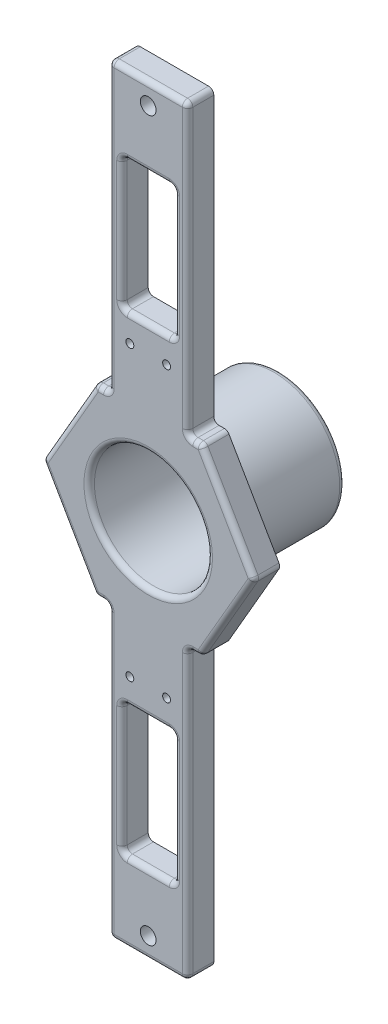
from build123d import *

# Parameters (mm, degrees)
BOSS_EXTRUDE2_DEPTH = 10
SKETCH4_W           = 30
SKETCH4_H           = 110
SKETCH4_R           = 1.5
BOSS_EXTRUDE4_DEPTH = 10
SKETCH5_R           = 3
CUT_EXTRUDE3_DEPTH  = 5
SKETCH6_W           = 4
SKETCH6_H           = 2
SKETCH6_W_2         = 2
SKETCH6_H_2         = 4
CUT_EXTRUDE4_DEPTH  = 4
CUT_EXTRUDE7_REACH  = 12
SKETCH13_W          = 20
SKETCH13_H          = 50
FILLET4_R           = 2
SKETCH14_R          = 25
BOSS_EXTRUDE5_DEPTH = 40
SKETCH15_R          = 22.5
CUT_EXTRUDE8_DEPTH  = 45
CUT_EXTRUDE9_REACH  = 52
SKETCH16_R          = 9
CUT_EXTRUDE10_REACH = 52
SKETCH17_R          = 2
FILLET5_R           = 2
FILLET6_R           = 2
CUT_EXTRUDE11_REACH = 52
CUT_EXTRUDE12_REACH = 52
SKETCH19_R          = 1.5
SKETCH20_R          = 3
CUT_EXTRUDE13_DEPTH = 5


with BuildPart() as part:
    # Sketch1 → Boss-Extrude2 (new body)
    with BuildSketch(Plane.XY):
        Polygon((20.207259422, 35), (-20.207259422, 35), (-40.414518843, 0), (-20.207259422, -35), (20.207259422, -35), (40.414518843, 0), align=None)
    extrude(amount=BOSS_EXTRUDE2_DEPTH)

    # Sketch4 → Boss-Extrude4 (add)
    with BuildSketch(Plane(origin=(0, 0, 0), x_dir=(-1, 0, 0), z_dir=(0, 0, -1))):
        with Locations((0, 90)):
            Rectangle(SKETCH4_W, SKETCH4_H)
        with Locations((0, 137)):
            Circle(SKETCH4_R, mode=Mode.SUBTRACT)
        with Locations((0, -90)):
            Rectangle(SKETCH4_W, SKETCH4_H)
        with Locations((0, -137)):
            Circle(SKETCH4_R, mode=Mode.SUBTRACT)
    extrude(amount=-BOSS_EXTRUDE4_DEPTH)

    # Sketch5 → Cut-Extrude3 (cut)
    with BuildSketch(Plane.XY.offset(10)):
        with Locations((0, 137)):
            Circle(SKETCH5_R)
        with Locations((0, -137)):
            Circle(SKETCH5_R)
    extrude(amount=-CUT_EXTRUDE3_DEPTH, mode=Mode.SUBTRACT)

    # Sketch6 → Cut-Extrude4 (cut)
    with BuildSketch(Plane(origin=(0, 0, 0), x_dir=(-1, 0, 0), z_dir=(0, 0, -1))):
        with Locations((5, 137)):
            Rectangle(SKETCH6_W, SKETCH6_H)
        with Locations((0, 142)):
            Rectangle(SKETCH6_W_2, SKETCH6_H_2)
        with Locations((0, 132)):
            Rectangle(SKETCH6_W_2, SKETCH6_H_2)
        with Locations((-5, 137)):
            Rectangle(SKETCH6_W, SKETCH6_H)
        with Locations((0, -132)):
            Rectangle(SKETCH6_W_2, SKETCH6_H_2)
        with Locations((5, -137)):
            Rectangle(SKETCH6_W, SKETCH6_H)
        with Locations((-5, -137)):
            Rectangle(SKETCH6_W, SKETCH6_H)
        with Locations((0, -142)):
            Rectangle(SKETCH6_W_2, SKETCH6_H_2)
    extrude(amount=-CUT_EXTRUDE4_DEPTH, mode=Mode.SUBTRACT)

    # Sketch13 → Cut-Extrude7 (cut, up to next)
    with BuildSketch(Plane.XY.offset(10), mode=Mode.PRIVATE) as cut_extrude7_sk1:
        with Locations((0, 90)):
            Rectangle(SKETCH13_W, SKETCH13_H)
    cut_extrude7_tool1 = extrude(cut_extrude7_sk1.sketch, amount=-CUT_EXTRUDE7_REACH, mode=Mode.PRIVATE) & part.part
    add(cut_extrude7_tool1.solids().sort_by_distance((0, 90, 10))[0], mode=Mode.SUBTRACT)
    # Sketch13 → Cut-Extrude7 (cut, up to next)
    with BuildSketch(Plane.XY.offset(10), mode=Mode.PRIVATE) as cut_extrude7_sk2:
        with Locations((0, -90)):
            Rectangle(SKETCH13_W, SKETCH13_H)
    cut_extrude7_tool2 = extrude(cut_extrude7_sk2.sketch, amount=-CUT_EXTRUDE7_REACH, mode=Mode.PRIVATE) & part.part
    add(cut_extrude7_tool2.solids().sort_by_distance((0, -90, 10))[0], mode=Mode.SUBTRACT)

    # Fillet4
    fillet4_edges = [part.edges().sort_by_distance(p)[0] for p in [
        (40.414518843, 0, 5),
        (20.207259422, -35, 5),
        (-20.207259422, -35, 5),
        (-40.414518843, 0, 5),
        (-20.207259422, 35, 5),
        (20.207259422, 35, 5),
        (-30.310889132, 17.5, 10),
        (-30.310889132, -17.5, 10),
        (-10, 65, 5),
        (-10, 115, 5),
        (10, 115, 5),
        (10, 65, 5),
        (-10, 90, 10),
        (0, 65, 10),
        (10, 90, 10),
        (0, 115, 10),
        (10, -65, 5),
        (10, -115, 5),
        (-10, -115, 5),
        (-10, -65, 5),
        (10, -90, 10),
        (0, -65, 10),
        (-10, -90, 10),
        (0, -115, 10),
        (-17.603629711, -35, 10),
        (17.603629711, -35, 10),
        (-17.603629711, 35, 10),
        (30.310889132, -17.5, 10),
        (15, 90, 10),
        (15, 35, 5),
        (0, 145, 10),
        (15, 145, 5),
        (-15, 90, 10),
        (-15, 145, 5),
        (-15, 35, 5),
        (15, -90, 10),
        (15, -145, 5),
        (15, -35, 5),
        (-15, -90, 10),
        (-15, -35, 5),
        (0, -145, 10),
        (-15, -145, 5),
        (30.310889132, 17.5, 10),
        (17.603629711, 35, 10),
    ]]
    fillet(fillet4_edges, radius=FILLET4_R)

    # Sketch14 → Boss-Extrude5 (add)
    with BuildSketch(Plane(origin=(0, 0, 0), x_dir=(-1, 0, 0), z_dir=(0, 0, -1))):
        Circle(SKETCH14_R)
    extrude(amount=BOSS_EXTRUDE5_DEPTH)

    # Sketch15 → Cut-Extrude8 (cut)
    with BuildSketch(Plane.XY.offset(10)):
        Circle(SKETCH15_R)
    extrude(amount=-CUT_EXTRUDE8_DEPTH, mode=Mode.SUBTRACT)

    # Sketch16 → Cut-Extrude9 (cut, up to next)
    with BuildSketch(Plane(origin=(0, 0, -40), x_dir=(-1, 0, 0), z_dir=(0, 0, -1)), mode=Mode.PRIVATE) as cut_extrude9_sk1:
        Circle(SKETCH16_R)
    cut_extrude9_tool1 = extrude(cut_extrude9_sk1.sketch, amount=-CUT_EXTRUDE9_REACH, mode=Mode.PRIVATE) & part.part
    add(cut_extrude9_tool1.solids().sort_by_distance((0, 0, -40))[0], mode=Mode.SUBTRACT)

    # Sketch17 → Cut-Extrude10 (cut, up to next)
    with BuildSketch(Plane(origin=(0, 0, -40), x_dir=(-1, 0, 0), z_dir=(0, 0, -1)), mode=Mode.PRIVATE) as cut_extrude10_sk1:
        with Locations((-14.5, 0)):
            Circle(SKETCH17_R)
    cut_extrude10_tool1 = extrude(cut_extrude10_sk1.sketch, amount=-CUT_EXTRUDE10_REACH, mode=Mode.PRIVATE) & part.part
    add(cut_extrude10_tool1.solids().sort_by_distance((14.5, 0, -40))[0], mode=Mode.SUBTRACT)
    # Sketch17 → Cut-Extrude10 (cut, up to next)
    with BuildSketch(Plane(origin=(0, 0, -40), x_dir=(-1, 0, 0), z_dir=(0, 0, -1)), mode=Mode.PRIVATE) as cut_extrude10_sk2:
        with Locations((14.5, 0)):
            Circle(SKETCH17_R)
    cut_extrude10_tool2 = extrude(cut_extrude10_sk2.sketch, amount=-CUT_EXTRUDE10_REACH, mode=Mode.PRIVATE) & part.part
    add(cut_extrude10_tool2.solids().sort_by_distance((-14.5, 0, -40))[0], mode=Mode.SUBTRACT)

    # Fillet5
    fillet5_edges = [part.edges().sort_by_distance(p)[0] for p in [
        (25, 0, -40),
    ]]
    fillet(fillet5_edges, radius=FILLET5_R)

    # Fillet6
    fillet6_edges = [part.edges().sort_by_distance(p)[0] for p in [
        (-22.5, 0, 10),
    ]]
    fillet(fillet6_edges, radius=FILLET6_R)

    # Sketch18 → Cut-Extrude11 (cut, up to next)
    with BuildSketch(Plane(origin=(0, 0, -40), x_dir=(-1, 0, 0), z_dir=(0, 0, -1)), mode=Mode.PRIVATE) as cut_extrude11_sk1:
        with BuildLine():
            Line((14.654211885, 7.583144073), (11.10167567, 5.744806116))
            ThreePointArc((11.10167567, 5.744806116), (8.838834765, 8.838834765), (5.744806116, 11.10167567))
            Line((5.744806116, 11.10167567), (7.583144073, 14.654211885))
            ThreePointArc((7.583144073, 14.654211885), (11.66726189, 11.66726189), (14.654211885, 7.583144073))
        make_face()
    cut_extrude11_tool1 = extrude(cut_extrude11_sk1.sketch, amount=-CUT_EXTRUDE11_REACH, mode=Mode.PRIVATE) & part.part
    add(cut_extrude11_tool1.solids().sort_by_distance((-10.155842, 10.155842, -40))[0], mode=Mode.SUBTRACT)
    # Sketch18 → Cut-Extrude11 (cut, up to next)
    with BuildSketch(Plane(origin=(0, 0, -40), x_dir=(-1, 0, 0), z_dir=(0, 0, -1)), mode=Mode.PRIVATE) as cut_extrude11_sk2:
        with BuildLine():
            Line((14.654211885, -7.583144073), (11.10167567, -5.744806116))
            ThreePointArc((11.10167567, -5.744806116), (8.838834765, -8.838834765), (5.744806116, -11.10167567))
            Line((5.744806116, -11.10167567), (7.583144073, -14.654211885))
            ThreePointArc((7.583144073, -14.654211885), (11.66726189, -11.66726189), (14.654211885, -7.583144073))
        make_face()
    cut_extrude11_tool2 = extrude(cut_extrude11_sk2.sketch, amount=-CUT_EXTRUDE11_REACH, mode=Mode.PRIVATE) & part.part
    add(cut_extrude11_tool2.solids().sort_by_distance((-10.155842, -10.155842, -40))[0], mode=Mode.SUBTRACT)
    # Sketch18 → Cut-Extrude11 (cut, up to next)
    with BuildSketch(Plane(origin=(0, 0, -40), x_dir=(-1, 0, 0), z_dir=(0, 0, -1)), mode=Mode.PRIVATE) as cut_extrude11_sk3:
        with BuildLine():
            Line((-7.583144073, -14.654211885), (-5.744806116, -11.10167567))
            ThreePointArc((-5.744806116, -11.10167567), (-8.838834765, -8.838834765), (-11.10167567, -5.744806116))
            Line((-11.10167567, -5.744806116), (-14.654211885, -7.583144073))
            ThreePointArc((-14.654211885, -7.583144073), (-11.66726189, -11.66726189), (-7.583144073, -14.654211885))
        make_face()
    cut_extrude11_tool3 = extrude(cut_extrude11_sk3.sketch, amount=-CUT_EXTRUDE11_REACH, mode=Mode.PRIVATE) & part.part
    add(cut_extrude11_tool3.solids().sort_by_distance((10.155842, -10.155842, -40))[0], mode=Mode.SUBTRACT)
    # Sketch18 → Cut-Extrude11 (cut, up to next)
    with BuildSketch(Plane(origin=(0, 0, -40), x_dir=(-1, 0, 0), z_dir=(0, 0, -1)), mode=Mode.PRIVATE) as cut_extrude11_sk4:
        with BuildLine():
            Line((-14.654211885, 7.583144073), (-11.10167567, 5.744806116))
            ThreePointArc((-11.10167567, 5.744806116), (-8.838834765, 8.838834765), (-5.744806116, 11.10167567))
            Line((-5.744806116, 11.10167567), (-7.583144073, 14.654211885))
            ThreePointArc((-7.583144073, 14.654211885), (-11.66726189, 11.66726189), (-14.654211885, 7.583144073))
        make_face()
    cut_extrude11_tool4 = extrude(cut_extrude11_sk4.sketch, amount=-CUT_EXTRUDE11_REACH, mode=Mode.PRIVATE) & part.part
    add(cut_extrude11_tool4.solids().sort_by_distance((10.155842, 10.155842, -40))[0], mode=Mode.SUBTRACT)

    # Sketch19 → Cut-Extrude12 (cut, up to next)
    with BuildSketch(Plane.XY.offset(10), mode=Mode.PRIVATE) as cut_extrude12_sk1:
        with Locations((-7, 55)):
            Circle(SKETCH19_R)
    cut_extrude12_tool1 = extrude(cut_extrude12_sk1.sketch, amount=-CUT_EXTRUDE12_REACH, mode=Mode.PRIVATE) & part.part
    add(cut_extrude12_tool1.solids().sort_by_distance((-7, 55, 10))[0], mode=Mode.SUBTRACT)
    # Sketch19 → Cut-Extrude12 (cut, up to next)
    with BuildSketch(Plane.XY.offset(10), mode=Mode.PRIVATE) as cut_extrude12_sk2:
        with Locations((7, 55)):
            Circle(SKETCH19_R)
    cut_extrude12_tool2 = extrude(cut_extrude12_sk2.sketch, amount=-CUT_EXTRUDE12_REACH, mode=Mode.PRIVATE) & part.part
    add(cut_extrude12_tool2.solids().sort_by_distance((7, 55, 10))[0], mode=Mode.SUBTRACT)
    # Sketch19 → Cut-Extrude12 (cut, up to next)
    with BuildSketch(Plane.XY.offset(10), mode=Mode.PRIVATE) as cut_extrude12_sk3:
        with Locations((7, -55)):
            Circle(SKETCH19_R)
    cut_extrude12_tool3 = extrude(cut_extrude12_sk3.sketch, amount=-CUT_EXTRUDE12_REACH, mode=Mode.PRIVATE) & part.part
    add(cut_extrude12_tool3.solids().sort_by_distance((7, -55, 10))[0], mode=Mode.SUBTRACT)
    # Sketch19 → Cut-Extrude12 (cut, up to next)
    with BuildSketch(Plane.XY.offset(10), mode=Mode.PRIVATE) as cut_extrude12_sk4:
        with Locations((-7, -55)):
            Circle(SKETCH19_R)
    cut_extrude12_tool4 = extrude(cut_extrude12_sk4.sketch, amount=-CUT_EXTRUDE12_REACH, mode=Mode.PRIVATE) & part.part
    add(cut_extrude12_tool4.solids().sort_by_distance((-7, -55, 10))[0], mode=Mode.SUBTRACT)

    # Sketch20 → Cut-Extrude13 (cut)
    with BuildSketch(Plane(origin=(0, 0, 0), x_dir=(-1, 0, 0), z_dir=(0, 0, -1))):
        with Locations((-7, -55)):
            Circle(SKETCH20_R)
        with Locations((7, -55)):
            Circle(SKETCH20_R)
        with Locations((-7, 55)):
            Circle(SKETCH20_R)
        with Locations((7, 55)):
            Circle(SKETCH20_R)
    extrude(amount=-CUT_EXTRUDE13_DEPTH, mode=Mode.SUBTRACT)


solid = part.part
